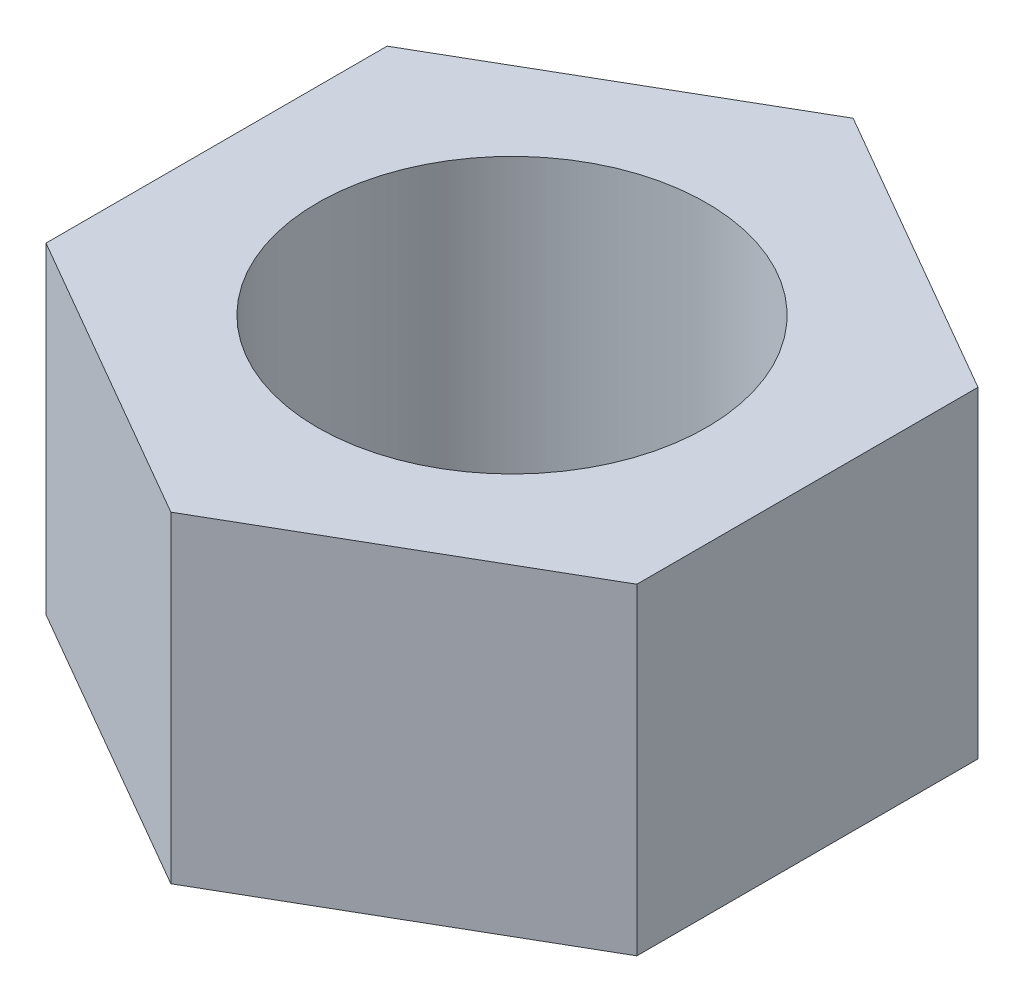
from build123d import *

# Parameters (mm, degrees)
SKETCH1_R           = 4.05
BOSS_EXTRUDE1_DEPTH = 6.7


with BuildPart() as part:
    # Sketch1 → Boss-Extrude1 (new body)
    with BuildSketch(Plane(origin=(0, 0, 0), x_dir=(1, 0, 0), z_dir=(0, 1, 0))):
        Polygon((3.167381974, -0.528493855), (3.167381974, 6.572914456), (-2.982618026, 10.123618611), (-9.132618026, 6.572914456), (-9.132618026, -0.528493855), (-2.982618026, -4.079198011), align=None)
        with Locations((-2.982618026, 3.0222103)):
            Circle(SKETCH1_R, mode=Mode.SUBTRACT)
    extrude(amount=BOSS_EXTRUDE1_DEPTH)


solid = part.part
